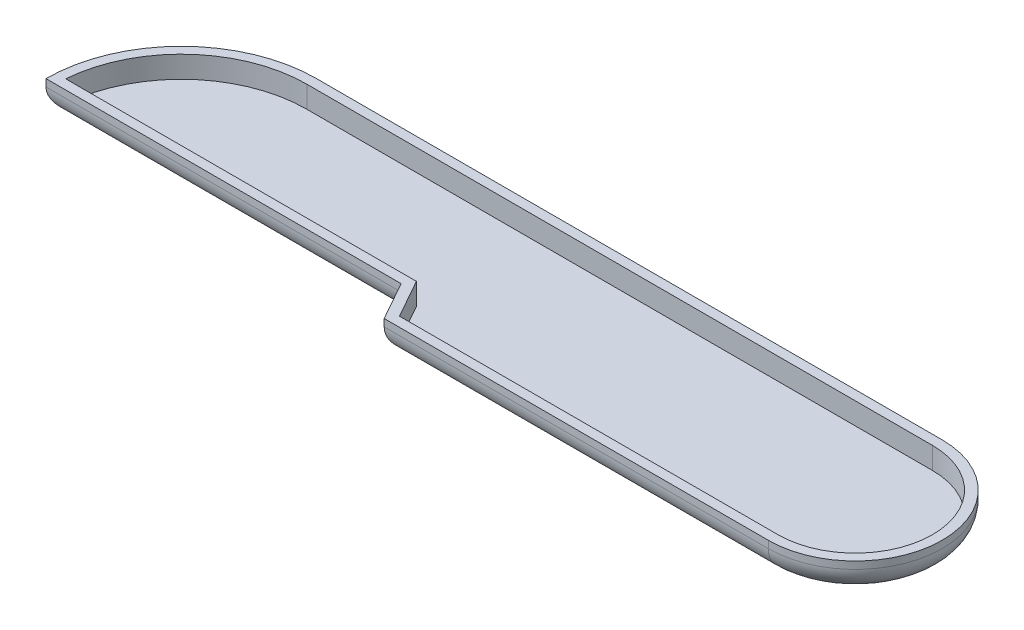
from build123d import *

# Parameters (mm, degrees)
BOSS_EXTRUDE1_DEPTH = 3.302
SHELL3_T            = -1.016
FILLET2_R           = 2.54


with BuildPart() as part:
    # Sketch1 → Boss-Extrude1 (new body)
    with BuildSketch(Plane(origin=(0, 0, 0), x_dir=(1, 0, 0), z_dir=(0, 1, 0))):
        with BuildLine():
            Line((0, 0), (65.786, 0))
            ThreePointArc((65.786, 0), (74.93, -9.144), (65.786, -18.288))
            Line((65.786, -18.288), (25.4, -18.288))
            Line((25.4, -18.288), (23.114, -14.224))
            Line((23.114, -14.224), (-14.224, -14.224))
            ThreePointArc((-14.224, -14.224), (-10.057886856, -4.166113144), (0, 0))
        make_face()
    extrude(amount=BOSS_EXTRUDE1_DEPTH)

    # Shell3
    shell3_openings = [part.faces().sort_by_distance(p)[0] for p in [
        (28.676685524, 3.302, 10.346352191),
    ]]
    offset(amount=SHELL3_T, openings=shell3_openings, kind=Kind.INTERSECTION)

    # Fillet2
    fillet2_edges = [part.edges().sort_by_distance(p)[0] for p in [
        (32.893, 0, 0),
        (74.93, 0, 9.144),
        (45.593, 0, 18.288),
        (24.257, 0, 16.256),
        (4.445, 0, 14.224),
        (-10.057886856, 0, 4.166113144),
    ]]
    fillet(fillet2_edges, radius=FILLET2_R)


solid = part.part
